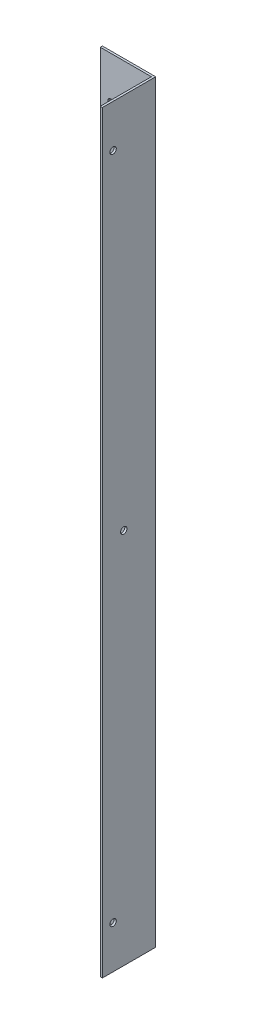
from build123d import *

# Parameters (mm, degrees)
CROQUIS2_W              = 1
CROQUIS2_H              = 354
SALIENTE_EXTRUIR2_DEPTH = 25
CROQUIS5_R              = 1.5
CORTAR_EXTRUIR2_DEPTH   = 1
CROQUIS1_W              = 24
CROQUIS1_H              = 354
CROQUIS1_R              = 1.5
SALIENTE_EXTRUIR3_DEPTH = 1


with BuildPart() as part:
    # Croquis2 → Saliente-Extruir2 (new body)
    with BuildSketch(Plane.XY):
        with Locations((-55.758230402, -111.819349421)):
            Rectangle(CROQUIS2_W, CROQUIS2_H)
    extrude(amount=SALIENTE_EXTRUIR2_DEPTH)

    # Croquis5 → Cortar-Extruir2 (cut)
    with BuildSketch(Plane(origin=(-55.258230402, 0, 0), x_dir=(0, 0, -1), z_dir=(1, 0, 0))):
        with Locations((-20, 45.180650579)):
            Circle(CROQUIS5_R)
        with Locations((-20, -268.819349421)):
            Circle(CROQUIS5_R)
        with Locations((-15, -111.819349421)):
            Circle(CROQUIS5_R)
    extrude(amount=-CORTAR_EXTRUIR2_DEPTH, mode=Mode.SUBTRACT)

    # Croquis1 → Saliente-Extruir3 (add)
    with BuildSketch(Plane.XY):
        with Locations((-68.258230402, -111.819349421)):
            Rectangle(CROQUIS1_W, CROQUIS1_H)
        with Locations((-75.258230402, 45.180650579)):
            Circle(CROQUIS1_R, mode=Mode.SUBTRACT)
        with Locations((-75.258230402, -268.819349421)):
            Circle(CROQUIS1_R, mode=Mode.SUBTRACT)
    extrude(amount=SALIENTE_EXTRUIR3_DEPTH)


solid = part.part
